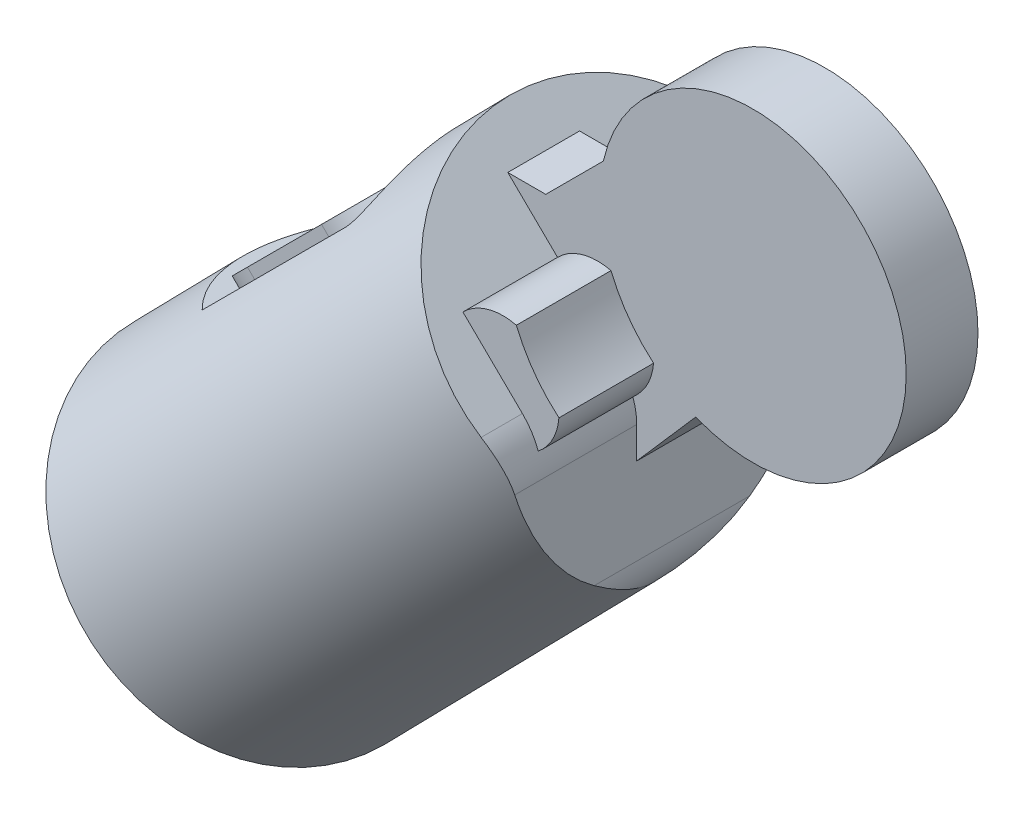
from build123d import *

# Parameters (mm, degrees)
SKETCH2_R               = 34.7138244
BOSS_EXTRUDE1_DEPTH     = 43.3659661
FILLET1_R               = 2.54
SKETCH4_R               = 34.7138244
CUT_EXTRUDE1_DEPTH      = 6.985
SKETCH5_R               = 33.813098677
BOSS_EXTRUDE2_DEPTH     = 104.394
CUT_EXTRUDE2_DEPTH      = 44.3659661
CUT_EXTRUDE2_DEPTH_BACK = 44.3659662
BOSS_EXTRUDE3_DEPTH     = 13.208
BOSS_EXTRUDE6_DEPTH     = 25.4
BOSS_EXTRUDE7_DEPTH     = 6.985
CUT_EXTRUDE3_DEPTH      = 44.3659661
CUT_EXTRUDE3_DEPTH_BACK = 44.3659662
CUT_EXTRUDE6_DEPTH      = 1.993615
SCALE2_SCALE            = 2.1025641


with BuildPart() as part:
    # Sketch2 → Boss-Extrude1 (new body, symmetric)
    with BuildSketch(Plane.XY):
        with Locations((-4.885886043, 8.460037767)):
            Circle(SKETCH2_R)
    extrude(amount=BOSS_EXTRUDE1_DEPTH, both=True)

    # Sketch3 → Revolve1 (revolve)
    with BuildSketch(Plane.XY):
        with BuildLine():
            Line((22.617188767, -2.954559536), (39.991940689, 15.756711766))
            ThreePointArc((39.991940689, 15.756711766), (40.875583615, 16.161668708), (41.78676132, 15.823186604))
            Line((41.78676132, 15.823186604), (42.898157249, 14.791176098))
            Line((42.898157249, 14.791176098), (48.074161234, 14.791176098))
            ThreePointArc((48.074161234, 14.791176098), (48.566620636, 14.890542194), (48.982018985, 15.173091472))
            Line((48.982018985, 15.173091472), (52.064778569, 18.324488421))
            Line((52.064778569, 18.324488421), (51.292291814, 19.080150428))
            Line((51.292291814, 19.080150428), (51.913951053, 19.715650854))
            Line((51.913951053, 19.715650854), (28.515190783, 42.604786571))
            Line((28.515190783, 42.604786571), (2.85696712, 16.37528486))
            Line((2.85696712, 16.37528486), (22.617188767, -2.954559536))
        make_face()
    revolve(axis=Axis((2.85696712, 16.37528486, 0), (0.699279233, 0.714848623, 0)))

    # Fillet1
    fillet1_edges = [part.edges().sort_by_distance(p)[0] for p in [
        (-39.599710443, 8.460037767, 43.3659661),
    ]]
    fillet(fillet1_edges, radius=FILLET1_R)

    # Sketch4 → Cut-Extrude1 (cut, symmetric)
    with BuildSketch(Plane.XY):
        with Locations((-4.885886043, 8.460037767)):
            Circle(SKETCH4_R)
    extrude(amount=CUT_EXTRUDE1_DEPTH, both=True, mode=Mode.SUBTRACT)

    # Sketch5 → Boss-Extrude2 (add)
    with BuildSketch(Plane(origin=(35.240913845, 36.025549629, 0), x_dir=(0.714848623, -0.699279233, 0), z_dir=(0.699279233, 0.714848623, 0))):
        with Locations((-9.408597634, 0)):
            Circle(SKETCH5_R)
    extrude(amount=BOSS_EXTRUDE2_DEPTH)

    # Sketch6 → Cut-Extrude2 (cut, two sides)
    with BuildSketch(Plane.XY) as cut_extrude2_sk:
        with BuildLine():
            Line((67.292407195, 130.59958962), (25.332730461, 87.705684449))
            Line((25.332730461, 87.705684449), (32.763241022, 90.002936951))
            Line((32.763241022, 90.002936951), (61.430101704, 118.669797633))
            add(Edge.make_bspline(
                [(61.430101704, 118.669797633), (64.563138592, 121.802834521), (65.338305365, 126.622992291), (67.292407195, 130.59958962)],
                knots=[0, 0, 0, 0, 1, 1, 1, 1], degree=3))
        make_face()
        with BuildLine():
            Line((108.792818243, 81.425512643), (108.918686949, 104.5771561))
            ThreePointArc((108.918686949, 104.5771561), (107.938557068, 109.538955465), (105.099720902, 113.72477877))
            Line((105.099720902, 113.72477877), (125.686994108, 93.585895982))
            Line((125.686994108, 93.585895982), (105.171583442, 72.613711538))
            ThreePointArc((105.171583442, 72.613711538), (107.839772529, 76.66719056), (108.792818243, 81.425512643))
        make_face()
    extrude(amount=CUT_EXTRUDE2_DEPTH, mode=Mode.SUBTRACT)
    extrude(cut_extrude2_sk.sketch, amount=-CUT_EXTRUDE2_DEPTH_BACK, mode=Mode.SUBTRACT)

    # Sketch12 → Boss-Extrude6 (add, symmetric)
    with BuildSketch(Plane.XY):
        with BuildLine():
            Line((93.516859048, 125.055366113), (105.099720902, 113.72477877))
            ThreePointArc((105.099720902, 113.72477877), (106.910314157, 111.50062472), (108.175689127, 108.926924007))
            ThreePointArc((108.175689127, 108.926924007), (110.974870017, 112.327766266), (112.202154604, 116.558004353))
            ThreePointArc((112.202154604, 116.558004353), (107.370575878, 121.792992409), (103.918241878, 128.024416235))
            ThreePointArc((103.918241878, 128.024416235), (98.323942367, 127.918806427), (93.516859048, 125.055366113))
        make_face()
    extrude(amount=BOSS_EXTRUDE6_DEPTH, both=True)

    # Sketch12_3 → Boss-Extrude7 (add, symmetric)
    with BuildSketch(Plane.XY):
        with BuildLine():
            ThreePointArc((112.202154604, 116.558004353), (110.168783957, 123.814558681), (103.918241878, 128.024416235))
            ThreePointArc((103.918241878, 128.024416235), (107.370575878, 121.792992409), (112.202154604, 116.558004353))
        make_face()
        with BuildLine():
            ThreePointArc((102.433332077, 145.737270979), (101.825593785, 136.767653772), (103.918241878, 128.024416235))
            ThreePointArc((103.918241878, 128.024416235), (110.168783957, 123.814558681), (112.202154604, 116.558004353))
            ThreePointArc((112.202154604, 116.558004353), (116.105893598, 113.74176866), (120.411822358, 111.590178756))
            ThreePointArc((120.411822358, 111.590178756), (148.242172435, 114.54403237), (161.372696963, 139.259269819))
            ThreePointArc((161.372696963, 139.259269819), (134.805522913, 168.906416529), (102.433332077, 145.737270979))
        make_face()
        with BuildLine():
            Line((83.835311865, 134.526049383), (93.516859048, 125.055366113))
            ThreePointArc((93.516859048, 125.055366113), (98.323942367, 127.918806427), (103.918241878, 128.024416235))
            ThreePointArc((103.918241878, 128.024416235), (101.825593785, 136.767653772), (102.433332077, 145.737270979))
            Line((102.433332077, 145.737270979), (91.222110481, 134.526049383))
            Line((91.222110481, 134.526049383), (83.835311865, 134.526049383))
        make_face()
        with BuildLine():
            ThreePointArc((112.202154604, 116.558004353), (110.974870017, 112.327766266), (108.175689127, 108.926924007))
            ThreePointArc((108.175689127, 108.926924007), (108.737557935, 106.784557747), (108.918686949, 104.5771561))
            Line((108.918686949, 104.5771561), (108.885067656, 98.393396013))
            Line((108.885067656, 98.393396013), (120.411822358, 111.590178756))
            ThreePointArc((120.411822358, 111.590178756), (116.105893598, 113.74176866), (112.202154604, 116.558004353))
        make_face()
    extrude(amount=BOSS_EXTRUDE7_DEPTH, both=True)

    # Sketch13 → Cut-Extrude3 (cut, two sides)
    with BuildSketch(Plane.XY) as cut_extrude3_sk:
        Polygon((-11.059857652, 81.317891206), (67.08361219, 4.876384648), (-5.062145194, -68.87569155), (-83.205615037, 7.565815008), align=None)
    extrude(amount=CUT_EXTRUDE3_DEPTH, mode=Mode.SUBTRACT)
    extrude(cut_extrude3_sk.sketch, amount=-CUT_EXTRUDE3_DEPTH_BACK, mode=Mode.SUBTRACT)


with BuildPart() as body_2:
    # Sketch8 → Boss-Extrude3 (new body, symmetric)
    with BuildSketch(Plane.XY):
        Polygon((31.287985123, 88.527681052), (29.878286463, 89.937379712), (60.29118565, 120.350278899), (63.299006413, 123.358099663), (64.708705073, 121.948401003), (61.430101704, 118.669797633), align=None)
    extrude(amount=BOSS_EXTRUDE3_DEPTH, both=True)

    # Sketch15 → Cut-Extrude6 (cut)
    with BuildSketch(Plane(origin=(-30.029546625, 30.029546625, 0), x_dir=(0, 0, 1), z_dir=(-0.707106781, 0.707106781, 0))):
        with BuildLine():
            ThreePointArc((13.208, 98.188075554), (0, 84.980075554), (-13.208, 98.188075554))
            Line((-13.208, 98.188075554), (-13.208, 84.722470044))
            Line((-13.208, 84.722470044), (13.208, 84.722470044))
            Line((13.208, 84.722470044), (13.208, 98.188075554))
        make_face()
        with BuildLine():
            Line((13.208, 131.986505463), (-13.208, 131.986505463))
            Line((-13.208, 131.986505463), (-13.208, 127.349860112))
            Line((-13.208, 127.349860112), (-13.208, 118.57593923))
            ThreePointArc((-13.208, 118.57593923), (0, 131.78393923), (13.208, 118.57593923))
            Line((13.208, 118.57593923), (13.208, 131.986505463))
        make_face()
    extrude(amount=-CUT_EXTRUDE6_DEPTH, mode=Mode.SUBTRACT)


with BuildPart() as body_2_1:
    # Scale2: scaled about (0, 0, 0)
    add(body_2.part.scale(SCALE2_SCALE))


with BuildPart() as part_1:
    # Scale2: scaled about (0, 0, 0)
    add(part.part.scale(SCALE2_SCALE))


solid = Compound([body_2_1.part, part_1.part])
